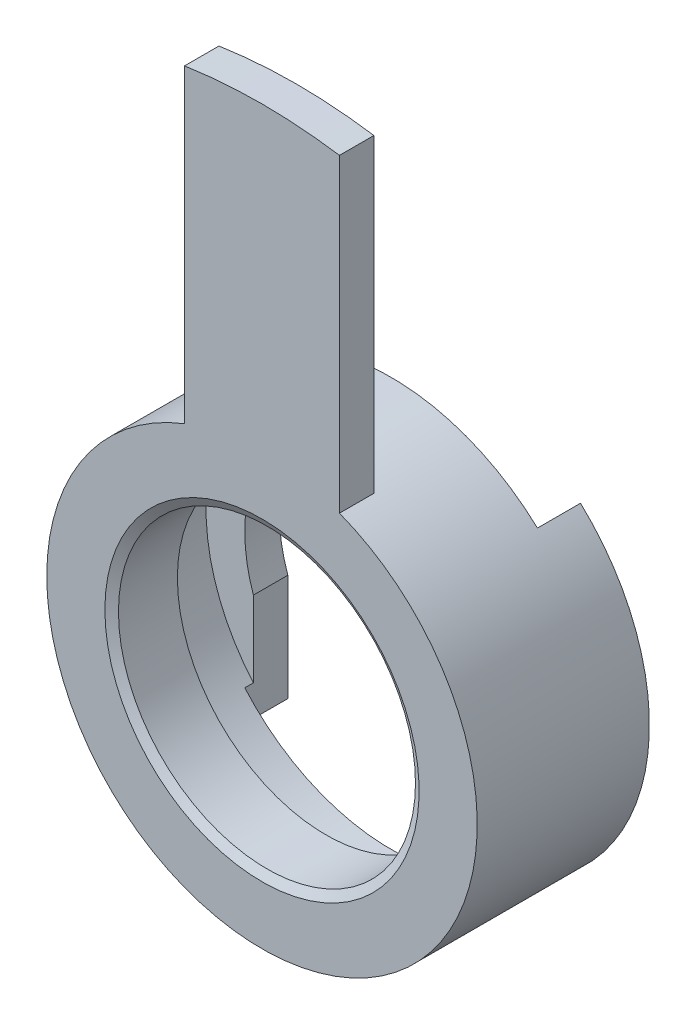
from build123d import *

# Parameters (mm, degrees)
CHAMFER_1_SIZE         = 1
CHAMFER_1_SIZE2        = 0.577350269
CHAMFER_1_PART_2_SIZE  = 1
CHAMFER_1_PART_2_SIZE2 = 0.577350269
CUT_EXTRUDE_1_DEPTH    = 5
CUT_EXTRUDE_2_DEPTH    = 5


with BuildPart() as part:
    # Эскиз1 → Повернуть1 (revolve)
    with BuildSketch(Plane(origin=(0, 0, 0), x_dir=(0, 0, -1), z_dir=(1, 0, 0))):
        Polygon((0, 17.25), (0, 60), (4, 60), (4, 25), (20, 25), (20, 18), (16, 18), (16, 22.5), (8, 22.5), (8, 17.25), align=None)
    revolve(axis=Axis((0, 0, 0), (0, 0, -1)))

    # Фаска1
    chamfer_1_edges = [part.edges().sort_by_distance(p)[0] for p in [
        (0, -17.25, 0),
    ]]
    chamfer_1_side = [part.faces().sort_by_distance(p)[0] for p in [
        (0, -18.947056275, 0),
    ]]
    chamfer(chamfer_1_edges, length=CHAMFER_1_SIZE, length2=CHAMFER_1_SIZE2, reference=chamfer_1_side[0])

    # Фаска1 part 2
    chamfer_1_part_2_edges = [part.edges().sort_by_distance(p)[0] for p in [
        (0, -17.25, -8),
    ]]
    chamfer_1_part_2_side = [part.faces().sort_by_distance(p)[0] for p in [
        (0, -21.863603897, -8),
    ]]
    chamfer(chamfer_1_part_2_edges, length=CHAMFER_1_PART_2_SIZE, length2=CHAMFER_1_PART_2_SIZE2, reference=chamfer_1_part_2_side[0])

    # Эскиз2 → Вырез-Вытянуть1 (cut)
    with BuildSketch(Plane(origin=(0, 0, -20), x_dir=(-1, 0, 0), z_dir=(0, 0, -1))):
        with BuildLine():
            ThreePointArc((17, 18.33030278), (0, 25), (-17, 18.33030278))
            Line((-17, 18.33030278), (-17, 5.916079783))
            ThreePointArc((-17, 5.916079783), (0, 18), (17, 5.916079783))
            Line((17, 5.916079783), (17, 18.33030278))
        make_face()
        with BuildLine():
            Line((-17, -5.916079783), (-17, -18.33030278))
            ThreePointArc((-17, -18.33030278), (0, -25), (17, -18.33030278))
            Line((17, -18.33030278), (17, -5.916079783))
            ThreePointArc((17, -5.916079783), (0, -18), (-17, -5.916079783))
        make_face()
    extrude(amount=-CUT_EXTRUDE_1_DEPTH, mode=Mode.SUBTRACT)

    # Эскиз3 → Вырез-Вытянуть2 (cut)
    with BuildSketch(Plane.XY):
        with BuildLine():
            Line((-9, 23.323807579), (-9, 59.3211598))
            ThreePointArc((-9, 59.3211598), (-39.115214431, -45.497252664), (60, 0))
            ThreePointArc((60, 0), (45.497252664, 39.115214431), (9, 59.3211598))
            Line((9, 59.3211598), (9, 23.323807579))
            ThreePointArc((9, 23.323807579), (20.615528128, 14.142135624), (25, 0))
            ThreePointArc((25, 0), (-14.142135624, -20.615528128), (-9, 23.323807579))
        make_face()
    extrude(amount=-CUT_EXTRUDE_2_DEPTH, mode=Mode.SUBTRACT)


solid = part.part
